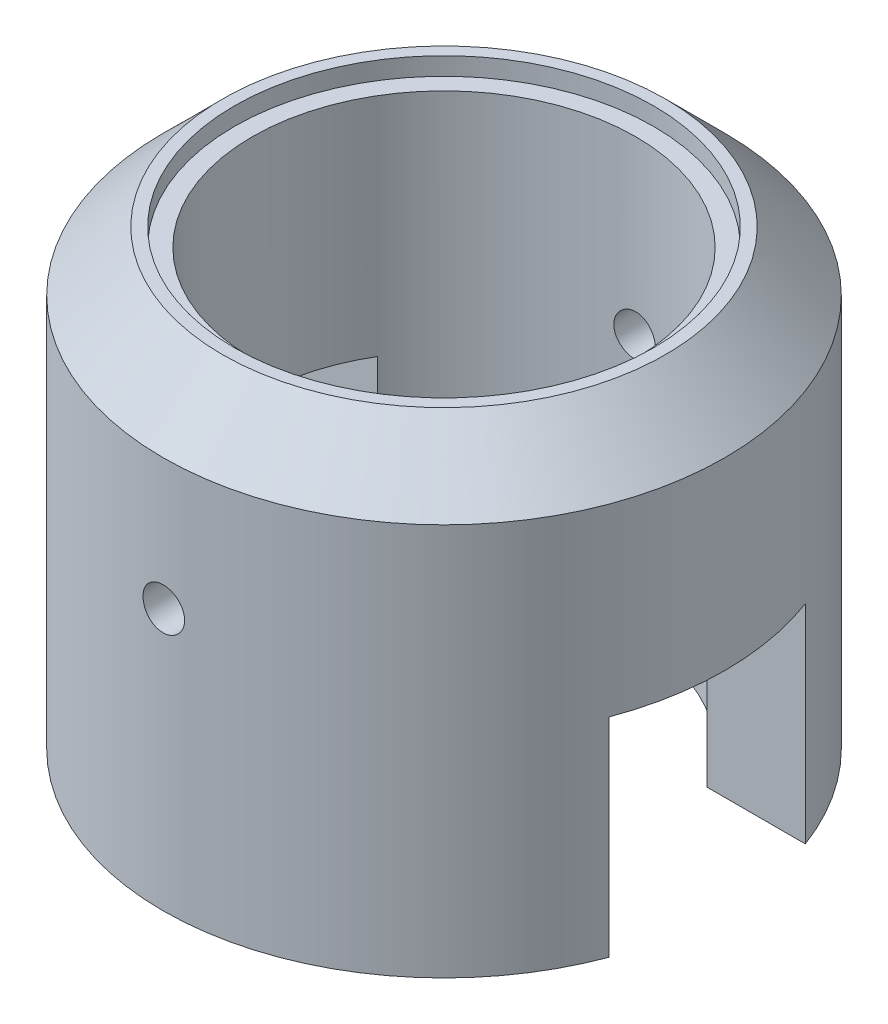
from build123d import *

# Parameters (mm, degrees)
CHAMFER1_SIZE           = 1
SKETCH2_W               = 3.3
SKETCH2_H               = 3.5
CUT_EXTRUDE1_DEPTH      = 5.725
CUT_EXTRUDE1_DEPTH_BACK = 5.725
SKETCH3_R               = 0.35
CUT_EXTRUDE2_DEPTH      = 5.725
CUT_EXTRUDE2_DEPTH_BACK = 5.725


with BuildPart() as part:
    # Sketch1 → Revolve1 (revolve)
    with BuildSketch(Plane.XY):
        Polygon((-4.725, 0), (-4.725, 7.6), (-3.525, 7.6), (-3.525, 7.3), (-3.225, 7.3), (-3.225, 0), align=None)
    revolve(axis=Axis((0, 7.611752988, 0), (0, -1, 0)))

    # Chamfer1
    chamfer1_edges = [part.edges().sort_by_distance(p)[0] for p in [
        (4.725, 7.6, 0),
    ]]
    chamfer(chamfer1_edges, length=CHAMFER1_SIZE)

    # Sketch2 → Cut-Extrude1 (cut, two sides)
    with BuildSketch(Plane(origin=(0, 0, 0), x_dir=(0, 0, -1), z_dir=(1, 0, 0))) as cut_extrude1_sk:
        with Locations((0, 1.75)):
            Rectangle(SKETCH2_W, SKETCH2_H)
    extrude(amount=CUT_EXTRUDE1_DEPTH, mode=Mode.SUBTRACT)
    extrude(cut_extrude1_sk.sketch, amount=-CUT_EXTRUDE1_DEPTH_BACK, mode=Mode.SUBTRACT)

    # Sketch3 → Cut-Extrude2 (cut, two sides)
    with BuildSketch(Plane.XY) as cut_extrude2_sk:
        with Locations((0, 4.4)):
            Circle(SKETCH3_R)
    extrude(amount=CUT_EXTRUDE2_DEPTH, mode=Mode.SUBTRACT)
    extrude(cut_extrude2_sk.sketch, amount=-CUT_EXTRUDE2_DEPTH_BACK, mode=Mode.SUBTRACT)


solid = part.part
